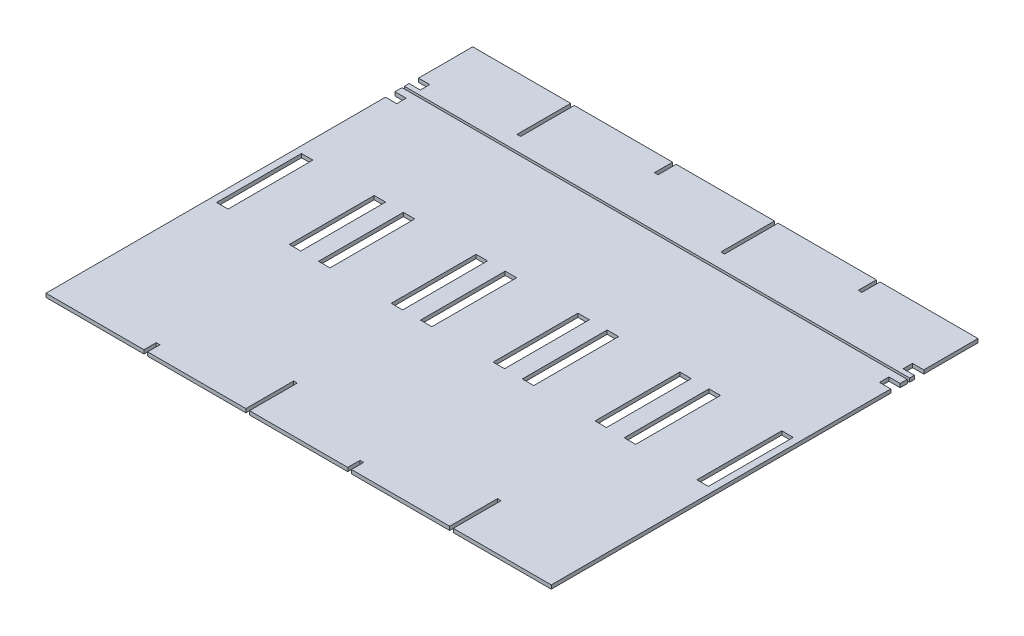
from build123d import *

# Parameters (mm, degrees)
SKETCH1_W           = 9.7
SKETCH1_H           = 71.96
BOSS_EXTRUDE1_DEPTH = 3.175
BOSS_EXTRUDE2_DEPTH = 3.175


with BuildPart() as part:
    # Sketch1 → Boss-Extrude1 (new body)
    with BuildSketch(Plane(origin=(0, 0, 0), x_dir=(1, 0, 0), z_dir=(0, 1, 0))):
        Polygon((-214.312, 121.0008), (-214.312, 115.0008), (-204.787, 115.0008), (-204.787, 107.0008), (-214.312, 107.0008), (-214.312, -181.0008), (-131.2076, -181.0008), (-131.2076, -170.612), (-128.1196, -170.612), (-128.1196, -181.0008), (-44.7652, -181.0008), (-44.7652, -140.472), (-41.6772, -140.472), (-41.6772, -181.0008), (41.6772, -181.0008), (41.6772, -170.612), (44.7652, -170.612), (44.7652, -181.0008), (128.1196, -181.0008), (128.1196, -140.472), (131.2076, -140.472), (131.2076, -181.0008), (214.312, -181.0008), (214.312, 107.0008), (204.787, 107.0008), (204.787, 115.0008), (214.312, 115.0008), (214.312, 121.0008), align=None)
        with Locations((-117.2876, -6.02)):
            Rectangle(SKETCH1_W, SKETCH1_H, mode=Mode.SUBTRACT)
        with Locations((-55.5876, -6.02)):
            Rectangle(SKETCH1_W, SKETCH1_H, mode=Mode.SUBTRACT)
        with Locations((-142.0276, -6.02)):
            Rectangle(SKETCH1_W, SKETCH1_H, mode=Mode.SUBTRACT)
        with Locations((-203.7276, -6.02)):
            Rectangle(SKETCH1_W, SKETCH1_H, mode=Mode.SUBTRACT)
        with Locations((30.8524, -6.02)):
            Rectangle(SKETCH1_W, SKETCH1_H, mode=Mode.SUBTRACT)
        with Locations((-30.8476, -6.02)):
            Rectangle(SKETCH1_W, SKETCH1_H, mode=Mode.SUBTRACT)
        with Locations((117.2924, -6.02)):
            Rectangle(SKETCH1_W, SKETCH1_H, mode=Mode.SUBTRACT)
        with Locations((55.5924, -6.02)):
            Rectangle(SKETCH1_W, SKETCH1_H, mode=Mode.SUBTRACT)
        with Locations((203.7324, -6.02)):
            Rectangle(SKETCH1_W, SKETCH1_H, mode=Mode.SUBTRACT)
        with Locations((142.0324, -6.02)):
            Rectangle(SKETCH1_W, SKETCH1_H, mode=Mode.SUBTRACT)
    extrude(amount=BOSS_EXTRUDE1_DEPTH)


with BuildPart() as body_2:
    # Sketch1_4 → Boss-Extrude2 (new body)
    with BuildSketch(Plane(origin=(0, 0, 0), x_dir=(1, 0, 0), z_dir=(0, 1, 0))):
        Polygon((-128.1196, 135.472), (-131.2076, 135.472), (-131.2076, 181.0008), (-214.312, 181.0008), (-214.312, 135.0008), (-204.787, 135.0008), (-204.787, 127.0008), (-214.312, 127.0008), (-214.312, 123.0008), (214.312, 123.0008), (214.312, 127.0008), (204.787, 127.0008), (204.787, 135.0008), (214.312, 135.0008), (214.312, 181.0008), (131.2076, 181.0008), (131.2076, 165.612), (128.1196, 165.612), (128.1196, 181.0008), (44.7652, 181.0008), (44.7652, 135.472), (41.6772, 135.472), (41.6772, 181.0008), (-41.6772, 181.0008), (-41.6772, 165.612), (-44.7652, 165.612), (-44.7652, 181.0008), (-128.1196, 181.0008), align=None)
    extrude(amount=BOSS_EXTRUDE2_DEPTH)


solid = Compound([part.part, body_2.part])
